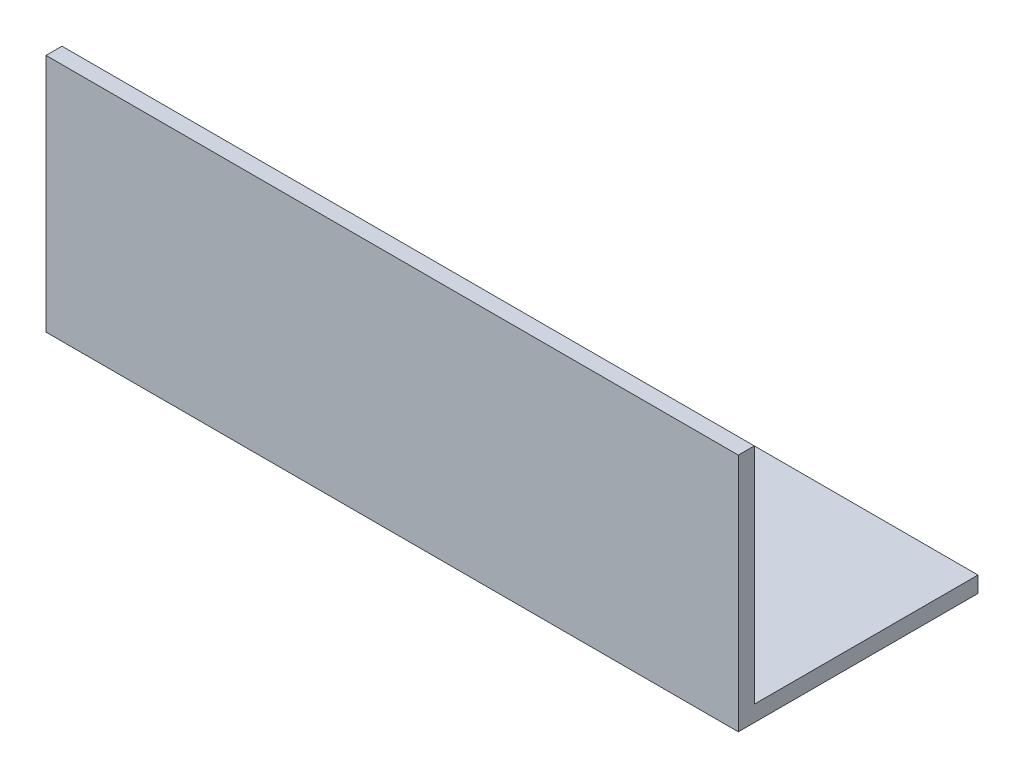
from build123d import *

# Parameters (mm, degrees)
EXTRUDE_1_DEPTH = 130


with BuildPart() as part:
    # Эскиз1 → Вытянуть-Тонкостенный1 (new body)
    with BuildSketch(Plane(origin=(0, 0, 0), x_dir=(0, 0, -1), z_dir=(1, 0, 0))):
        Polygon((45, 0), (0, 0), (0, 45), (3, 45), (3, 3), (45, 3), align=None)
    extrude(amount=EXTRUDE_1_DEPTH)


solid = part.part
